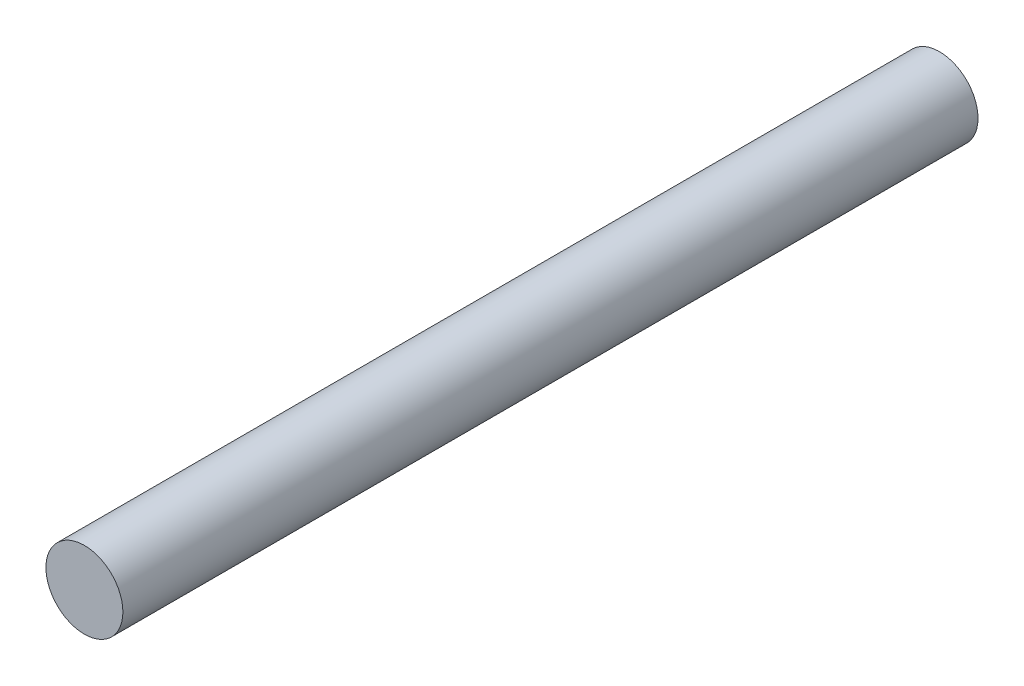
from build123d import *

# Parameters (mm, degrees)
SKETCH1_R           = 9
BOSS_EXTRUDE1_DEPTH = 200


with BuildPart() as part:
    # Sketch1 → Boss-Extrude1 (new body)
    with BuildSketch(Plane.XY):
        Circle(SKETCH1_R)
    extrude(amount=BOSS_EXTRUDE1_DEPTH)


solid = part.part
